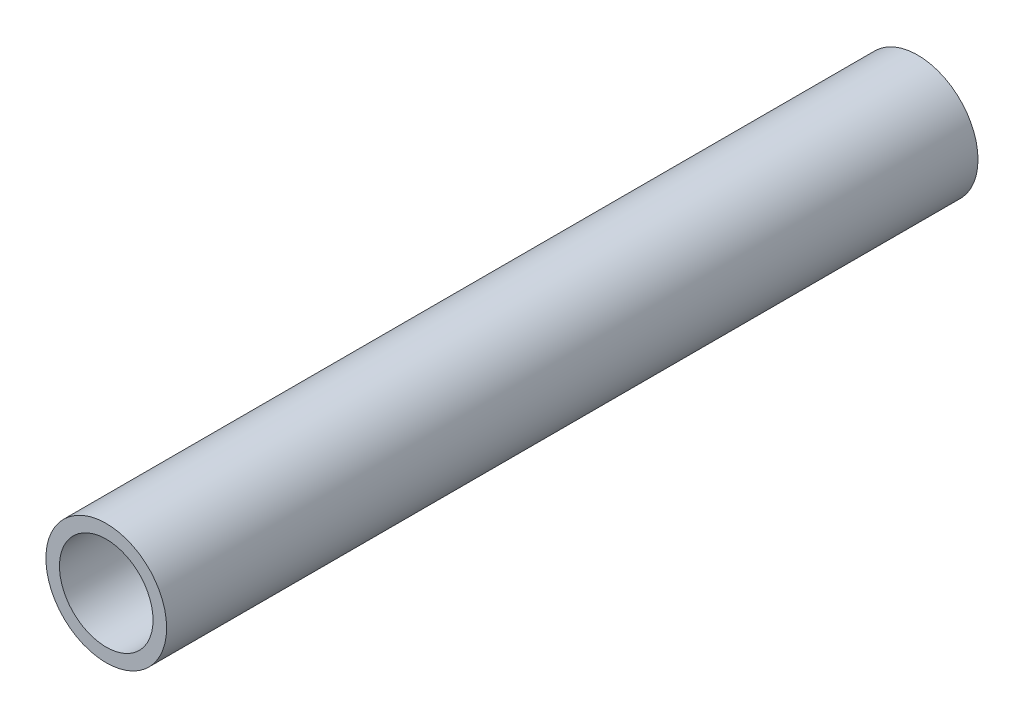
from build123d import *

# Parameters (mm, degrees)
SKETCH1_R           = 50.8
SKETCH1_R_2         = 39.37
BOSS_EXTRUDE1_DEPTH = 682.752


with BuildPart() as part:
    # Sketch1 → Boss-Extrude1 (new body)
    with BuildSketch(Plane.XY):
        Circle(SKETCH1_R)
        Circle(SKETCH1_R_2, mode=Mode.SUBTRACT)
    extrude(amount=BOSS_EXTRUDE1_DEPTH)


solid = part.part
